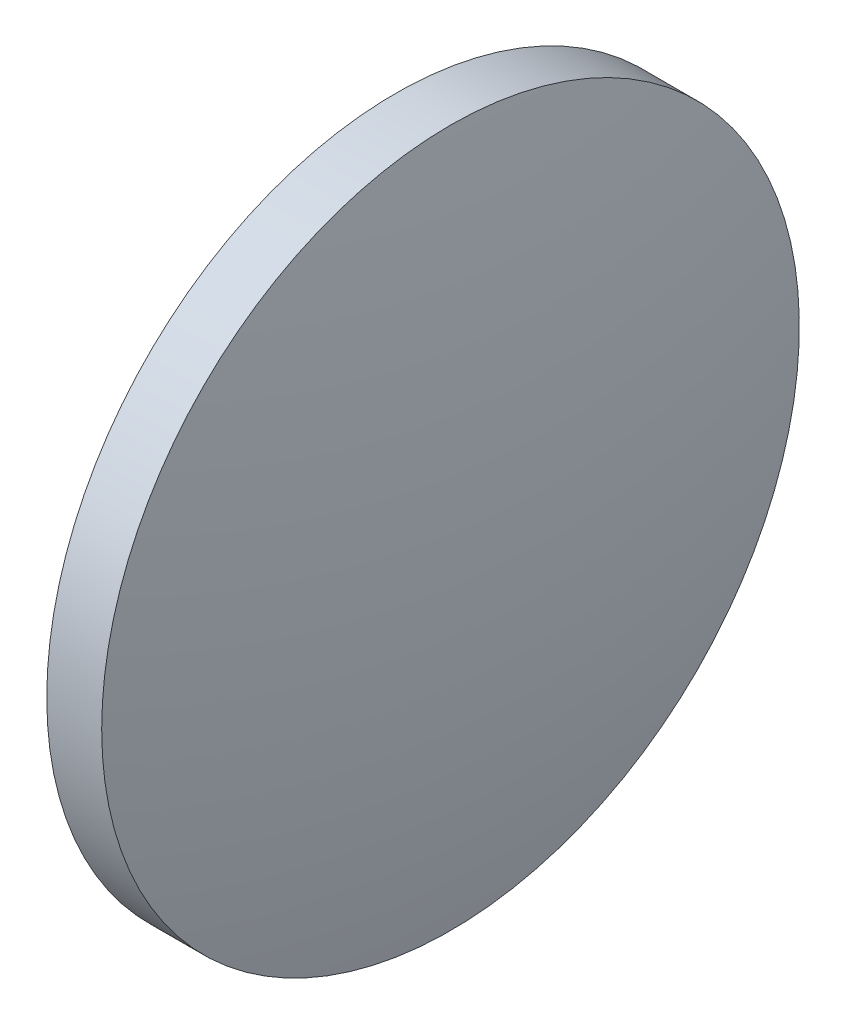
from build123d import *


with BuildPart() as part:
    # 草图1 → 旋转1 (revolve)
    with BuildSketch(Plane.XY):
        with BuildLine():
            Line((449.841609705, 96.724279513), (449.841609705, 109.424279513))
            Line((449.841609705, 109.424279513), (451.841609705, 109.424279513))
            ThreePointArc((451.841609705, 109.424279513), (452.815762797, 103.107460538), (453.141609705, 96.724279513))
            Line((453.141609705, 96.724279513), (449.841609705, 96.724279513))
        make_face()
    revolve(axis=Axis((444.103391669, 96.724279513, 0), (1, 0, 0)))


solid = part.part
